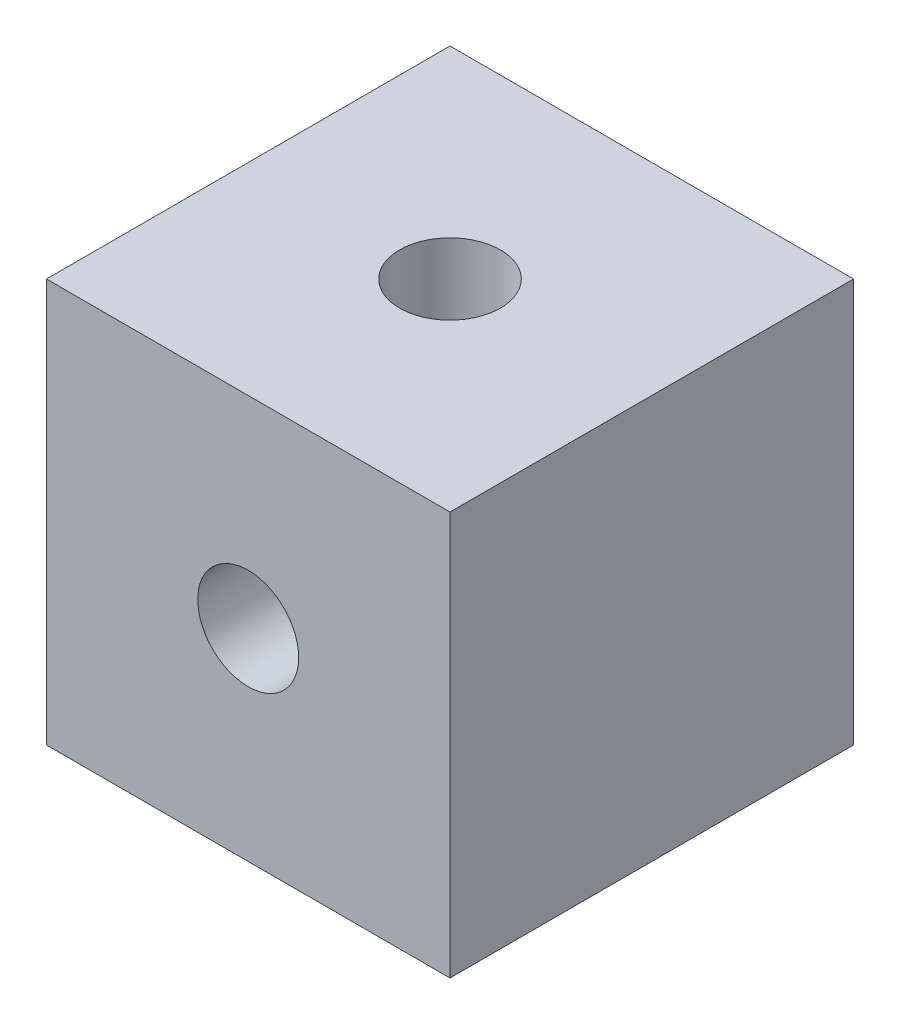
from build123d import *

# Parameters (mm, degrees)
SKETCH1_W           = 25.4
SKETCH1_H           = 25.4
BOSS_EXTRUDE1_DEPTH = 25.4
SKETCH2_R           = 3.175
CUT_EXTRUDE1_DEPTH  = 12.7
SKETCH3_R           = 3.175
CUT_EXTRUDE2_DEPTH  = 12.7


with BuildPart() as part:
    # Sketch1 → Boss-Extrude1 (new body)
    with BuildSketch(Plane.XY):
        Rectangle(SKETCH1_W, SKETCH1_H)
    extrude(amount=BOSS_EXTRUDE1_DEPTH)

    # Sketch2 → Cut-Extrude1 (cut)
    with BuildSketch(Plane.XY.offset(25.4)):
        Circle(SKETCH2_R)
    extrude(amount=-CUT_EXTRUDE1_DEPTH, mode=Mode.SUBTRACT)

    # Sketch3 → Cut-Extrude2 (cut)
    with BuildSketch(Plane(origin=(0, 12.7, 0), x_dir=(1, 0, 0), z_dir=(0, 1, 0))):
        with Locations((0, -12.7)):
            Circle(SKETCH3_R)
    extrude(amount=-CUT_EXTRUDE2_DEPTH, mode=Mode.SUBTRACT)


solid = part.part
